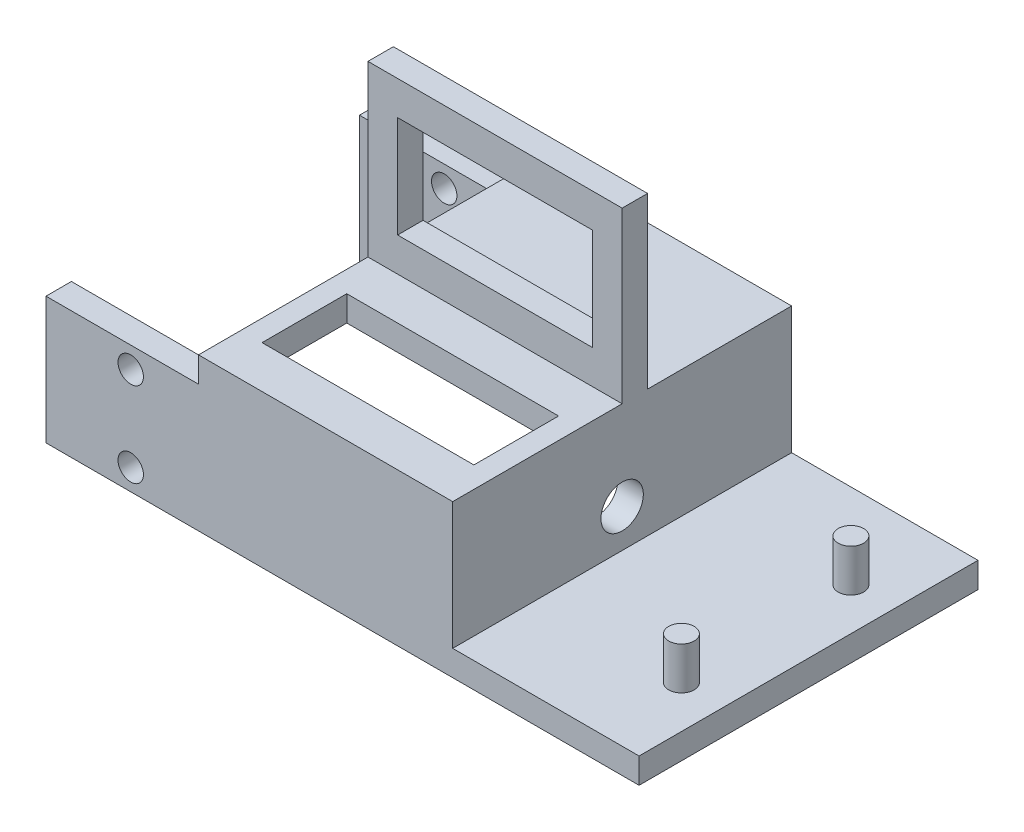
from build123d import *

# Parameters (mm, degrees)
BOSS_EXTRUDE1_DEPTH     = 40
SKETCH2_R               = 1.5
BOSS_EXTRUDE2_DEPTH     = 5
SKETCH3_R               = 2.5
CUT_EXTRUDE1_DEPTH      = 50.497474683
CUT_EXTRUDE1_DEPTH_BACK = 50.497474683
SKETCH4_W               = 45
SKETCH4_H               = 15
BOSS_EXTRUDE3_DEPTH     = 3
SKETCH5_W               = 45
SKETCH5_H               = 15
BOSS_EXTRUDE4_DEPTH     = 3
SKETCH6_R               = 1.5
CUT_EXTRUDE2_DEPTH      = 63.04836823
CUT_EXTRUDE2_DEPTH_BACK = 63.04836823
SKETCH8_W               = 30
SKETCH8_H               = 40
SKETCH8_W_2             = 25
SKETCH8_H_2             = 10
BOSS_EXTRUDE7_DEPTH     = 3
BOSS_EXTRUDE8_DEPTH     = 3


with BuildPart() as part:
    # Sketch1 → Boss-Extrude1 (new body)
    with BuildSketch(Plane.XY):
        Polygon((0, 0), (25, 0), (25, 3), (3, 3), (3, 15), (0, 15), align=None)
    extrude(amount=BOSS_EXTRUDE1_DEPTH)

    # Sketch2 → Boss-Extrude2 (add)
    with BuildSketch(Plane(origin=(0, 3, 0), x_dir=(1, 0, 0), z_dir=(0, 1, 0))):
        with Locations((20, -10)):
            Circle(SKETCH2_R)
        with Locations((20, -30)):
            Circle(SKETCH2_R)
    extrude(amount=BOSS_EXTRUDE2_DEPTH)

    # Sketch3 → Cut-Extrude1 (cut, two sides)
    with BuildSketch(Plane.ZY) as cut_extrude1_sk:
        with Locations(Location((20, 7.5, 0), (0, 0, 270))):
            Circle(SKETCH3_R)
    extrude(amount=CUT_EXTRUDE1_DEPTH, mode=Mode.SUBTRACT)
    extrude(cut_extrude1_sk.sketch, amount=-CUT_EXTRUDE1_DEPTH_BACK, mode=Mode.SUBTRACT)

    # Sketch4 → Boss-Extrude3 (add)
    with BuildSketch(Plane(origin=(0, 0, 0), x_dir=(-1, 0, 0), z_dir=(0, 0, -1))):
        with Locations((22.5, 7.5)):
            Rectangle(SKETCH4_W, SKETCH4_H)
    extrude(amount=-BOSS_EXTRUDE3_DEPTH)

    # Sketch5 → Boss-Extrude4 (add)
    with BuildSketch(Plane.XY.offset(40)):
        with Locations((-22.5, 7.5)):
            Rectangle(SKETCH5_W, SKETCH5_H)
    extrude(amount=-BOSS_EXTRUDE4_DEPTH)

    # Sketch6 → Cut-Extrude2 (cut, two sides)
    with BuildSketch(Plane.XY.offset(40)) as cut_extrude2_sk:
        with Locations((-35, 12.5)):
            Circle(SKETCH6_R)
        with Locations((-35, 2.5)):
            Circle(SKETCH6_R)
    extrude(amount=CUT_EXTRUDE2_DEPTH, mode=Mode.SUBTRACT)
    extrude(cut_extrude2_sk.sketch, amount=-CUT_EXTRUDE2_DEPTH_BACK, mode=Mode.SUBTRACT)

    # Sketch8 → Boss-Extrude7 (add)
    with BuildSketch(Plane(origin=(0, 15, 0), x_dir=(1, 0, 0), z_dir=(0, 1, 0))):
        with Locations((-12, -20)):
            Rectangle(SKETCH8_W, SKETCH8_H)
        with Locations((-12, -30)):
            Rectangle(SKETCH8_W_2, SKETCH8_H_2, mode=Mode.SUBTRACT)
    extrude(amount=BOSS_EXTRUDE7_DEPTH)

    # 3DSketch1 → Boss-Extrude8 (add)
    with BuildSketch(Plane(origin=(-27, 18, 20), x_dir=(0.8320502943378437, 0.5547001962252291, 0), z_dir=(0, 0, -1))):
        Polygon((0, 0), (24.96150883, 16.641005887), (36.055512755, 0), (11.094003925, -16.641005887), align=None)
        Polygon((11.78737917, -11.371354023), (30.92453594, 1.386750491), (24.268133585, 11.371354023), (5.130976815, -1.386750491), align=None, mode=Mode.SUBTRACT)
    extrude(amount=BOSS_EXTRUDE8_DEPTH)


solid = part.part
